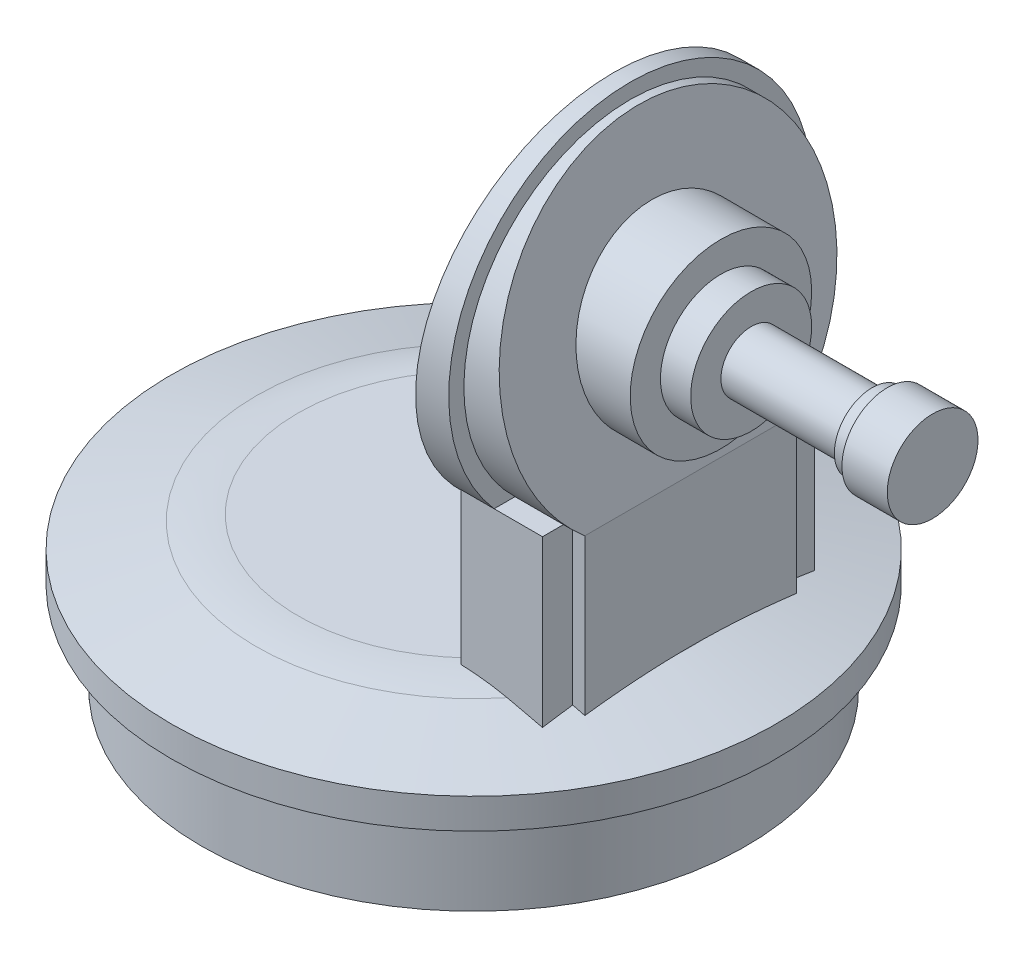
from build123d import *

# Parameters (mm, degrees)
SKETCH2_R                = 90
BOSS_EXTRUDE1_DEPTH      = 30
SKETCH3_R                = 100
BOSS_EXTRUDE2_DEPTH      = 20
CHAMFER1_SIZE            = 10
CHAMFER1_SIZE2           = 34.874144438
FILLET1_R                = 50
BOSS_EXTRUDE4_DEPTH      = 50
BOSS_EXTRUDE4_DEPTH_BACK = 5
SKETCH6_R                = 60
BOSS_EXTRUDE5_DEPTH      = 15
SKETCH7_R                = 55
SKETCH7_R_2              = 30
BOSS_EXTRUDE7_DEPTH      = 20
SKETCH9_W                = 143.392234206
SKETCH9_H                = 131.269767686
CUT_EXTRUDE1_DEPTH       = 20
SKETCH11_W               = 139.139474439
SKETCH11_H               = 119.959032869
CUT_EXTRUDE2_DEPTH       = 20
SKETCH7_4_R              = 30
BOSS_EXTRUDE9_DEPTH      = 30
SKETCH12_R               = 20
BOSS_EXTRUDE10_DEPTH     = 10
SKETCH13_R               = 10
BOSS_EXTRUDE11_DEPTH     = 40
SKETCH14_R               = 12.5
BOSS_EXTRUDE12_DEPTH     = 5
CUT_EXTRUDE3_START       = -15
SKETCH7_5_R              = 30
CUT_EXTRUDE3_DEPTH       = 15
SKETCH16_R               = 15
BOSS_EXTRUDE13_DEPTH     = 15
SCALE1_SCALE             = 0.3


with BuildPart() as part:
    # Sketch2 → Boss-Extrude1 (new body)
    with BuildSketch(Plane(origin=(0, 0, 0), x_dir=(1, 0, 0), z_dir=(0, 1, 0))):
        Circle(SKETCH2_R)
    extrude(amount=BOSS_EXTRUDE1_DEPTH)

    # Sketch3 → Boss-Extrude2 (add)
    with BuildSketch(Plane(origin=(0, 30, 0), x_dir=(1, 0, 0), z_dir=(0, 1, 0))):
        Circle(SKETCH3_R)
    extrude(amount=BOSS_EXTRUDE2_DEPTH)

    # Chamfer1
    chamfer1_edges = [part.edges().sort_by_distance(p)[0] for p in [
        (-100, 50, 0),
    ]]
    chamfer1_side = [part.faces().sort_by_distance(p)[0] for p in [
        (-100, 40, 0),
    ]]
    chamfer(chamfer1_edges, length=CHAMFER1_SIZE, length2=CHAMFER1_SIZE2, reference=chamfer1_side[0])

    # Fillet1
    fillet1_edges = [part.edges().sort_by_distance(p)[0] for p in [
        (-65.125855562, 50, 0),
    ]]
    fillet(fillet1_edges, radius=FILLET1_R)

    # Sketch5 → Boss-Extrude4 (add, two sides: drawn at the far end of the back side and taken through both)
    with BuildSketch(Plane(origin=(0, 50, 0), x_dir=(1, 0, 0), z_dir=(0, 1, 0)).offset(-BOSS_EXTRUDE4_DEPTH_BACK)):
        Polygon((40.748770973, -45), (67.748770973, -45), (67.748770973, -35), (71.748770973, -35), (71.748770973, 35), (67.748770973, 35), (67.748770973, 45), (40.748770973, 45), (40.748770973, 35), (36.748770973, 35), (36.748770973, -35), (40.748770973, -35), align=None)
    extrude(amount=BOSS_EXTRUDE4_DEPTH + BOSS_EXTRUDE4_DEPTH_BACK)

    # Sketch6 → Boss-Extrude5 (add)
    with BuildSketch(Plane.ZY.offset(-51.748770973)):
        with Locations((0, 139.686269666)):
            Circle(SKETCH6_R)
    extrude(amount=BOSS_EXTRUDE5_DEPTH)

    # Sketch7 → Boss-Extrude7 (add)
    with BuildSketch(Plane(origin=(51.748770973, 0, 0), x_dir=(0, 0, -1), z_dir=(1, 0, 0))):
        with Locations((0, 139.686269666)):
            Circle(SKETCH7_R)
        with Locations((0, 139.686269666)):
            Circle(SKETCH7_R_2, mode=Mode.SUBTRACT)
    extrude(amount=BOSS_EXTRUDE7_DEPTH)

    # Sketch9 → Cut-Extrude1 (cut)
    with BuildSketch(Plane(origin=(28.572772375, -2.499793668, 0), x_dir=(0, 0, 1), z_dir=(0.9961946980917461, -0.08715574274765156, 0))):
        with Locations((-2.562372985, -148.809625911)):
            Rectangle(SKETCH9_W, SKETCH9_H)
    extrude(amount=-CUT_EXTRUDE1_DEPTH, mode=Mode.SUBTRACT)

    # Sketch11 → Cut-Extrude2 (cut)
    with BuildSketch(Plane(origin=(86.21769691, 15.20250618, 0), x_dir=(0, 0, -1), z_dir=(-0.9848077530122091, -0.17364817766692414, 0))):
        with Locations((-5.201475679, -131.70762118)):
            Rectangle(SKETCH11_W, SKETCH11_H)
    extrude(amount=-CUT_EXTRUDE2_DEPTH, mode=Mode.SUBTRACT)

    # Sketch7_4 → Boss-Extrude9 (add)
    with BuildSketch(Plane(origin=(51.748770973, 0, 0), x_dir=(0, 0, -1), z_dir=(1, 0, 0))):
        with Locations((0, 139.686269666)):
            Circle(SKETCH7_4_R)
    extrude(amount=BOSS_EXTRUDE9_DEPTH)

    # Sketch12 → Boss-Extrude10 (add)
    with BuildSketch(Plane(origin=(81.748770973, 0, 0), x_dir=(0, 0, -1), z_dir=(1, 0, 0))):
        with Locations((0, 139.686269666)):
            Circle(SKETCH12_R)
    extrude(amount=BOSS_EXTRUDE10_DEPTH)

    # Sketch13 → Boss-Extrude11 (add)
    with BuildSketch(Plane(origin=(91.748770973, 0, 0), x_dir=(0, 0, -1), z_dir=(1, 0, 0))):
        with Locations((0, 139.686269666)):
            Circle(SKETCH13_R)
    extrude(amount=BOSS_EXTRUDE11_DEPTH)

    # Sketch14 → Boss-Extrude12 (add)
    with BuildSketch(Plane(origin=(131.748770973, 0, 0), x_dir=(0, 0, -1), z_dir=(1, 0, 0))):
        with Locations((0, 139.686269666)):
            Circle(SKETCH14_R)
    extrude(amount=BOSS_EXTRUDE12_DEPTH)

    # Sketch7_5 → Cut-Extrude3 (cut)
    with BuildSketch(Plane(origin=(51.748770973, 0, 0), x_dir=(0, 0, -1), z_dir=(1, 0, 0)).offset(CUT_EXTRUDE3_START)):
        with Locations((0, 139.686269666)):
            Circle(SKETCH7_5_R)
    extrude(amount=CUT_EXTRUDE3_DEPTH, mode=Mode.SUBTRACT)

    # Sketch16 → Boss-Extrude13 (add)
    with BuildSketch(Plane(origin=(136.748770973, 0, 0), x_dir=(0, 0, -1), z_dir=(1, 0, 0))):
        with Locations((0, 139.686269666)):
            Circle(SKETCH16_R)
    extrude(amount=BOSS_EXTRUDE13_DEPTH)


with BuildPart() as part_1:
    # Scale1: scaled about (14.94649503, 46.643113712, 0)
    add(part.part.scale(SCALE1_SCALE).moved(Location((10.462546521, 32.650179598, 0))))


solid = part_1.part
